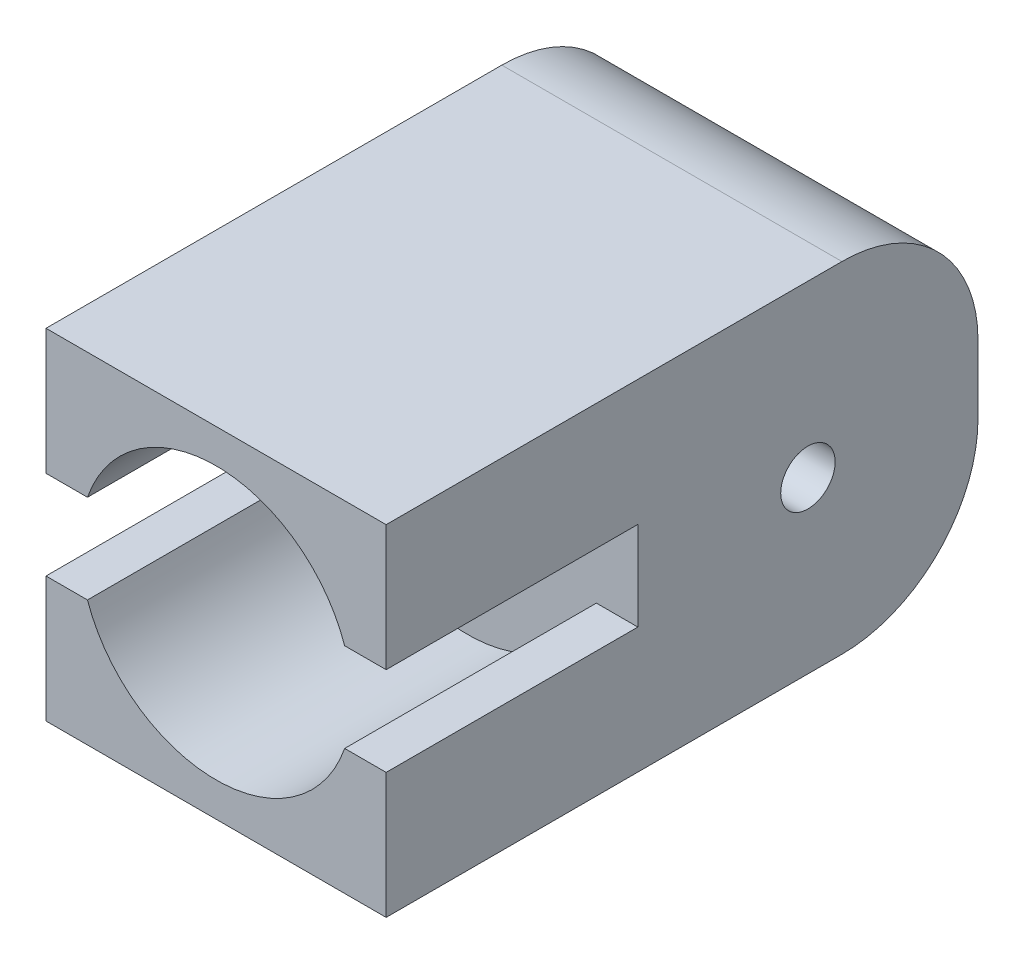
from build123d import *

# Parameters (mm, degrees)
EXTRUDE_1_DEPTH     = 37
EXTRUDE_1_2_DEPTH   = 37
SKETCH_1_4_W        = 50
SKETCH_1_4_H        = 50
EXTRUDE_2_DEPTH     = 50
SKETCH_3_R          = 4
CUT_EXTRUDE_1_DEPTH = 54
FILLET_1_R          = 20


with BuildPart() as part:
    # 스케치1 → 보스-돌출1 (new body)
    with BuildSketch(Plane.XY):
        with BuildLine():
            Line((-25, 25), (-25, 6.535008171))
            Line((-25, 6.535008171), (-18.902213315, 6.535008171))
            ThreePointArc((-18.902213315, 6.535008171), (0, 20), (18.902213315, 6.535008171))
            Line((18.902213315, 6.535008171), (25, 6.535008171))
            Line((25, 6.535008171), (25, 25))
            Line((25, 25), (-25, 25))
        make_face()
    extrude(amount=EXTRUDE_1_DEPTH)



with BuildPart() as body_2:
    # 스케치1 → Extrude 1 2 (new body)
    with BuildSketch(Plane.XY):
        with BuildLine():
            Line((-18.902213315, -6.535008171), (-25, -6.535008171))
            Line((-25, -6.535008171), (-25, -25))
            Line((-25, -25), (25, -25))
            Line((25, -25), (25, -6.535008171))
            Line((25, -6.535008171), (18.902213315, -6.535008171))
            ThreePointArc((18.902213315, -6.535008171), (0, -20), (-18.902213315, -6.535008171))
        make_face()
    extrude(amount=EXTRUDE_1_2_DEPTH)


with BuildPart() as part_1:
    add(part.part)

    add(body_2.part)  # 보스-돌출2 merges body 2
    # 스케치1<4> → 보스-돌출2 (add)
    with BuildSketch(Plane.XY):
        Rectangle(SKETCH_1_4_W, SKETCH_1_4_H)
    extrude(amount=-EXTRUDE_2_DEPTH)

    # 스케치3 → 컷-돌출1 (cut)
    with BuildSketch(Plane.ZY.offset(25)):
        with Locations((-25, 0)):
            Circle(SKETCH_3_R)
    extrude(amount=-CUT_EXTRUDE_1_DEPTH, mode=Mode.SUBTRACT)

    # 필렛1
    fillet_1_edges = [part_1.edges().sort_by_distance(p)[0] for p in [
        (0, -25, -50),
        (0, 25, -50),
    ]]
    fillet(fillet_1_edges, radius=FILLET_1_R)


solid = part_1.part
